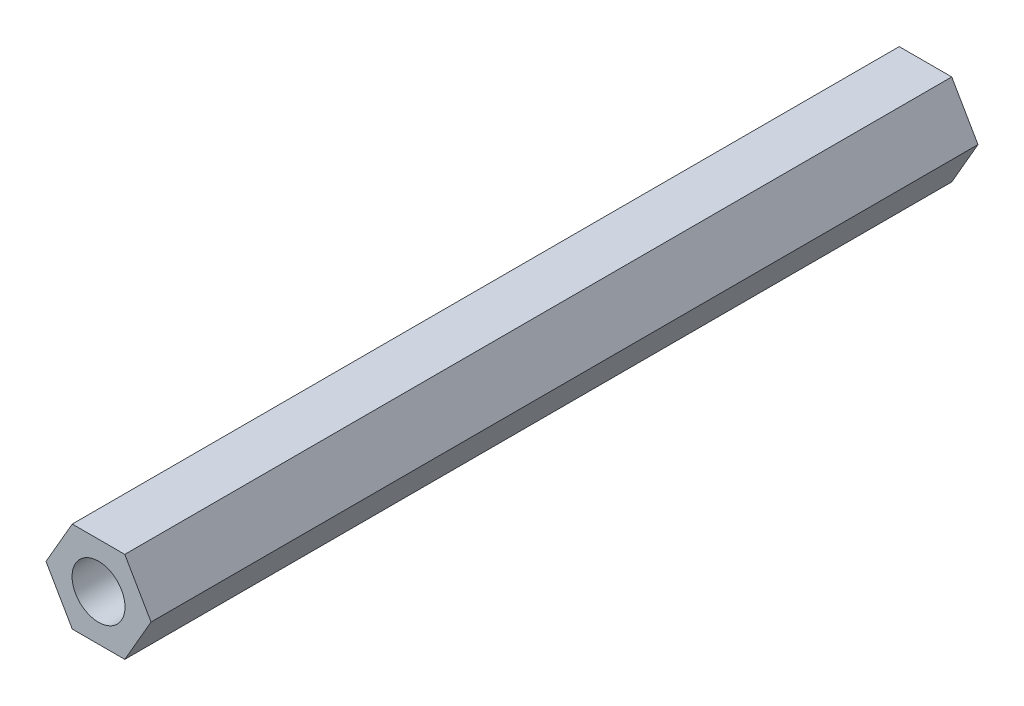
from build123d import *

# Parameters (mm, degrees)
SKETCH1_R           = 1.6
BOSS_EXTRUDE1_DEPTH = 50


with BuildPart() as part:
    # Sketch1 → Boss-Extrude1 (new body)
    with BuildSketch(Plane.XY):
        Polygon((-1.58771324, 2.75), (1.58771324, 2.75), (3.175426481, 0), (1.58771324, -2.75), (-1.58771324, -2.75), (-3.175426481, 0), align=None)
        Circle(SKETCH1_R, mode=Mode.SUBTRACT)
    extrude(amount=BOSS_EXTRUDE1_DEPTH)


solid = part.part
